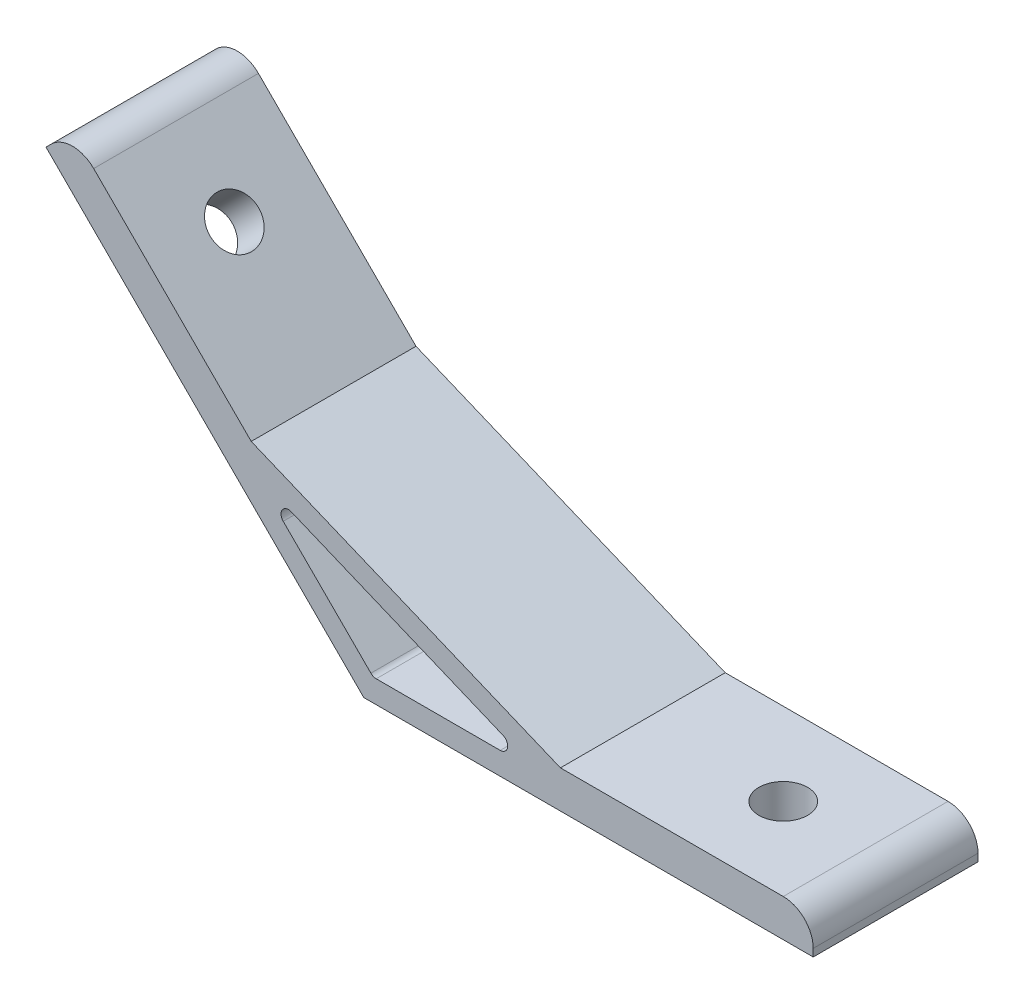
from build123d import *

# Parameters (mm, degrees)
EXTRUDE_1_DEPTH     = 11
SKETCH_2_R          = 3.25
CUT_EXTRUDE_1_DEPTH = 5
SKETCH_3_R          = 3.25
CUT_EXTRUDE_2_DEPTH = 5
FILLET_1_R          = 4
FILLET_2_R          = 1


with BuildPart() as part:
    # Эскиз1 → Бобышка-Вытянуть1 (new body, symmetric)
    with BuildSketch(Plane.XY):
        Polygon((0, 0), (-42.426406871, 42.426406871), (-38.890872965, 45.961940777), (-15.028558569, 22.099626381), (26.253591352, 5), (60, 5), (60, 0), align=None)
        Polygon((-14.313708499, 18.556349186), (23.242640687, 3), (1.242640687, 3), align=None, mode=Mode.SUBTRACT)
    extrude(amount=EXTRUDE_1_DEPTH, both=True)

    # Эскиз2 → Вырез-Вытянуть1 (cut)
    with BuildSketch(Plane(origin=(0, 0, 0), x_dir=(0, 0, 1), z_dir=(-0.707106781, -0.707106781, 0))):
        with Locations(Location((0, 45, 0), (0, 0, 270))):  # turned: the seam where the file's is
            Circle(SKETCH_2_R)
    extrude(amount=-CUT_EXTRUDE_1_DEPTH, mode=Mode.SUBTRACT)

    # Эскиз3 → Вырез-Вытянуть2 (cut)
    with BuildSketch(Plane.XZ):
        with Locations(Location((45, 0, 0), (0, 0, 270))):  # turned: the seam where the file's is
            Circle(SKETCH_3_R)
    extrude(amount=-CUT_EXTRUDE_2_DEPTH, mode=Mode.SUBTRACT)

    # Скругление1
    fillet_1_edges = [part.edges().sort_by_distance(p)[0] for p in [
        (-38.890872965, 45.961940777, 0),
        (60, 5, 0),
    ]]
    fillet(fillet_1_edges, radius=FILLET_1_R)

    # Скругление2
    fillet_2_edges = [part.edges().sort_by_distance(p)[0] for p in [
        (-14.313708499, 18.556349186, 0),
        (1.242640687, 3, 0),
        (23.242640687, 3, 0),
    ]]
    fillet(fillet_2_edges, radius=FILLET_2_R)


solid = part.part
